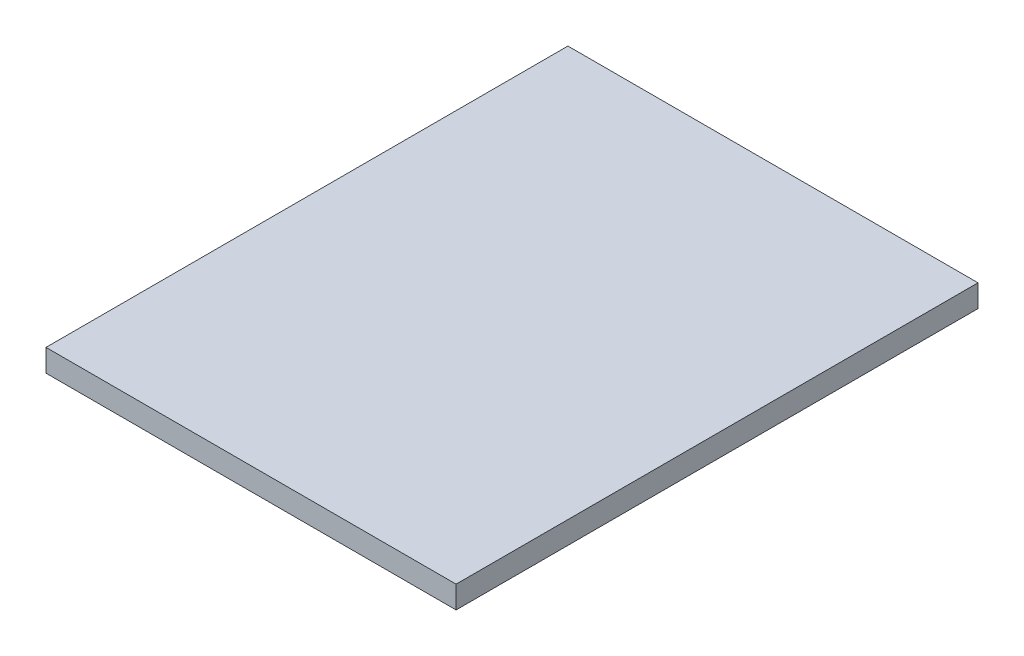
from build123d import *

# Parameters (mm, degrees)
SKETCH1_W           = 22
SKETCH1_H           = 28
BOSS_EXTRUDE1_DEPTH = 1.2


with BuildPart() as part:
    # Sketch1 → Boss-Extrude1 (new body)
    with BuildSketch(Plane(origin=(0, 0, 0), x_dir=(1, 0, 0), z_dir=(0, 1, 0))):
        Rectangle(SKETCH1_W, SKETCH1_H)
    extrude(amount=BOSS_EXTRUDE1_DEPTH)


solid = part.part
